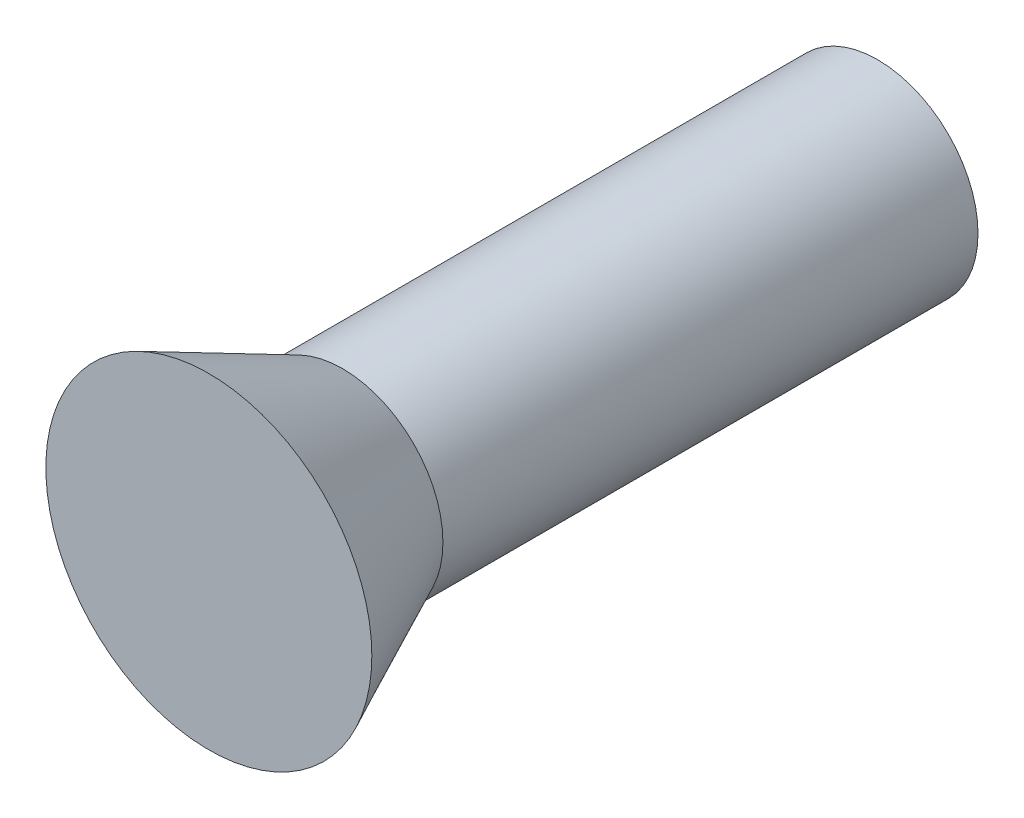
from build123d import *


with BuildPart() as part:
    # Эскиз1 → Повернуть1 (revolve)
    with BuildSketch(Plane(origin=(0, 0, 0), x_dir=(1, 0, 0), z_dir=(0, 1, 0))):
        Polygon((0, 10), (1.5, 10), (1.5, 2), (2.437083452, 0), (0, 0), align=None)
    revolve(axis=Axis((0, 0, 0), (0, 0, -1)))


solid = part.part
